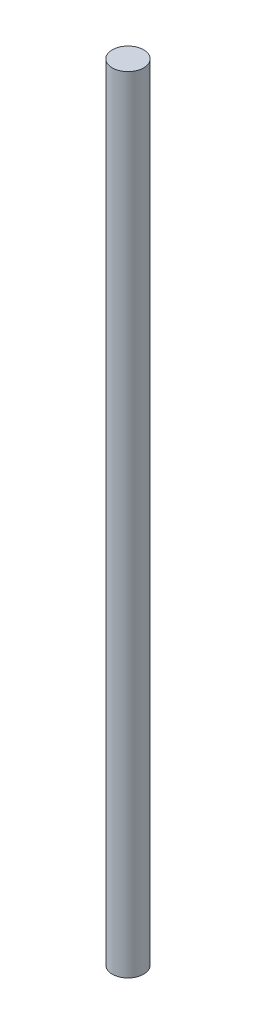
from build123d import *

# Parameters (mm, degrees)
SKETCH_1_R      = 4
EXTRUDE_1_DEPTH = 200


with BuildPart() as part:
    # 草图1 → 凸台-拉伸1 (new body)
    with BuildSketch(Plane(origin=(0, 0, 0), x_dir=(1, 0, 0), z_dir=(0, 1, 0))):
        Circle(SKETCH_1_R)
    extrude(amount=EXTRUDE_1_DEPTH)


solid = part.part
